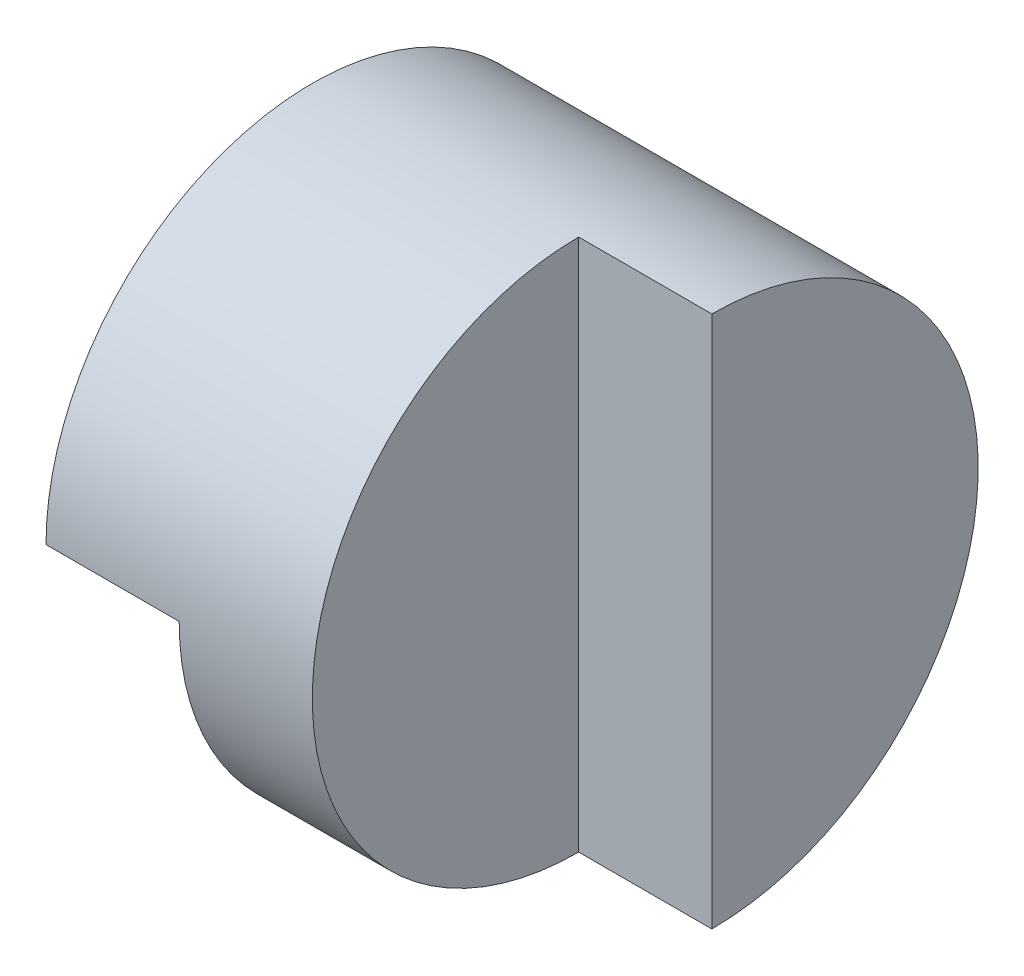
from build123d import *

# Parameters (mm, degrees)
SKETCH1_W           = 40
SKETCH1_H           = 40
BOSS_EXTRUDE1_DEPTH = 40
SKETCH2_W           = 10
SKETCH2_H           = 20
CUT_EXTRUDE1_DEPTH  = 40
CUT_EXTRUDE2_DEPTH  = 40
CUT_EXTRUDE3_DEPTH  = 40
CUT_EXTRUDE4_DEPTH  = 20
CUT_EXTRUDE5_DEPTH  = 10


with BuildPart() as part:
    # Sketch1 → Boss-Extrude1 (new body)
    with BuildSketch(Plane.XY):
        with Locations((20, 20)):
            Rectangle(SKETCH1_W, SKETCH1_H)
    extrude(amount=BOSS_EXTRUDE1_DEPTH)

    # Sketch2 → Cut-Extrude1 (cut)
    with BuildSketch(Plane.XY.offset(40)):
        with Locations((5, 30)):
            Rectangle(SKETCH2_W, SKETCH2_H)
    extrude(amount=-CUT_EXTRUDE1_DEPTH, mode=Mode.SUBTRACT)

    # Sketch3 → Cut-Extrude2 (cut)
    with BuildSketch(Plane.ZY.offset(-10)):
        with BuildLine():
            Line((0, 40), (0, 20))
            ThreePointArc((0, 20), (5.857864376, 34.142135624), (20, 40))
            Line((20, 40), (0, 40))
        make_face()
        with BuildLine():
            Line((40, 40), (20, 40))
            ThreePointArc((20, 40), (34.142135624, 34.142135624), (40, 20))
            Line((40, 20), (40, 40))
        make_face()
    extrude(amount=-CUT_EXTRUDE2_DEPTH, mode=Mode.SUBTRACT)

    # Sketch4 → Cut-Extrude3 (cut)
    with BuildSketch(Plane.ZY):
        with BuildLine():
            ThreePointArc((20, 0), (5.857864376, 5.857864376), (0, 20))
            Line((0, 20), (0, 0))
            Line((0, 0), (20, 0))
        make_face()
        with BuildLine():
            ThreePointArc((40, 20), (34.142135624, 5.857864376), (20, 0))
            Line((20, 0), (40, 0))
            Line((40, 0), (40, 20))
        make_face()
    extrude(amount=-CUT_EXTRUDE3_DEPTH, mode=Mode.SUBTRACT)

    # Sketch5 → Cut-Extrude4 (cut)
    with BuildSketch(Plane.ZY):
        with BuildLine():
            Line((20, 0), (20, 20))
            Line((20, 20), (40, 20))
            ThreePointArc((40, 20), (34.142135624, 5.857864376), (20, 0))
        make_face()
    extrude(amount=-CUT_EXTRUDE4_DEPTH, mode=Mode.SUBTRACT)

    # Sketch6 → Cut-Extrude5 (cut)
    with BuildSketch(Plane(origin=(40, 0, 0), x_dir=(0, 0, -1), z_dir=(1, 0, 0))):
        with BuildLine():
            Line((-20, 40), (-20, 0))
            ThreePointArc((-20, 0), (-40, 20), (-20, 40))
        make_face()
    extrude(amount=-CUT_EXTRUDE5_DEPTH, mode=Mode.SUBTRACT)


solid = part.part
